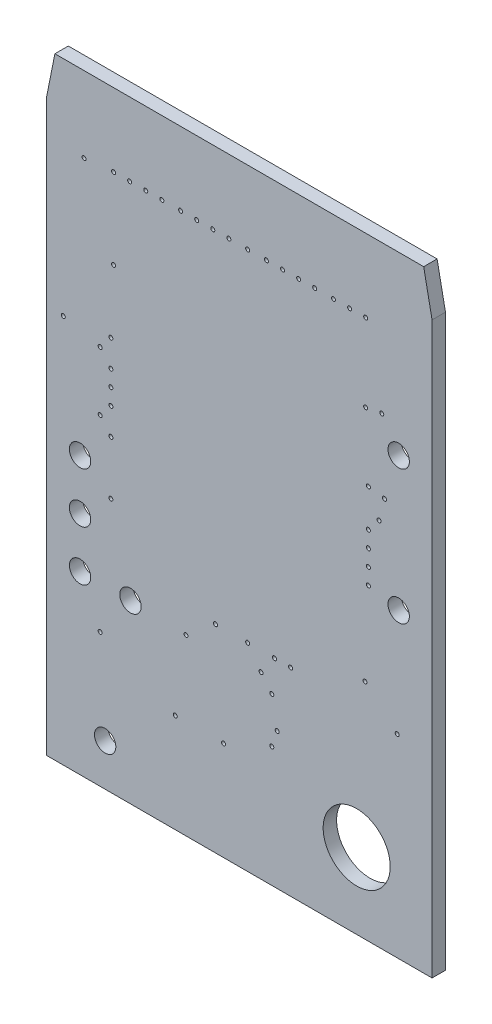
from build123d import *

# Parameters (mm, degrees)
BOARD_OUTLINE_DEPTH = 0.508
SKETCH2_R           = 0.0762
NPTH_DEPTH          = 1.508
SKETCH3_R           = 0.405
SKETCH3_R_2         = 1.27
PTH_DEPTH           = 1.508


with BuildPart() as part:
    # Sketch1 → Board_Outline (new body)
    with BuildSketch(Plane.XY):
        Polygon((0, 0), (0, 21.59), (0.3175, 23.1775), (14.2875, 23.1775), (14.605, 21.59), (14.605, 0), align=None)
    extrude(amount=BOARD_OUTLINE_DEPTH)

    # Sketch2 → NPTH (cut, through all)
    with BuildSketch(Plane.XY):
        with Locations((1.4224, 20.3073)):
            Circle(SKETCH2_R)
        with Locations((8.5344, 4.5593)):
            Circle(SKETCH2_R)
        with Locations((12.7, 17.5641)):
            Circle(SKETCH2_R)
        with Locations((12.065, 8.4582)):
            Circle(SKETCH2_R)
        with Locations((13.2842, 7.3406)):
            Circle(SKETCH2_R)
        with Locations((0.635, 14.732)):
            Circle(SKETCH2_R)
        with Locations((3.1496, 20.4089)):
            Circle(SKETCH2_R)
        with Locations((2.4384, 14.9225)):
            Circle(SKETCH2_R)
        with Locations((2.54, 20.4089)):
            Circle(SKETCH2_R)
        with Locations((2.54, 17.3609)):
            Circle(SKETCH2_R)
        with Locations((3.7592, 20.4089)):
            Circle(SKETCH2_R)
        with Locations((2.032, 14.4145)):
            Circle(SKETCH2_R)
        with Locations((4.3688, 20.4089)):
            Circle(SKETCH2_R)
        with Locations((2.4384, 13.9065)):
            Circle(SKETCH2_R)
        with Locations((5.08, 20.4089)):
            Circle(SKETCH2_R)
        with Locations((2.4384, 13.2969)):
            Circle(SKETCH2_R)
        with Locations((5.6896, 20.4089)):
            Circle(SKETCH2_R)
        with Locations((2.4384, 12.6873)):
            Circle(SKETCH2_R)
        with Locations((6.2992, 20.4089)):
            Circle(SKETCH2_R)
        with Locations((2.032, 12.1793)):
            Circle(SKETCH2_R)
        with Locations((6.9088, 20.4089)):
            Circle(SKETCH2_R)
        with Locations((2.4384, 11.6713)):
            Circle(SKETCH2_R)
        with Locations((7.62, 20.4089)):
            Circle(SKETCH2_R)
        with Locations((12.192, 11.6713)):
            Circle(SKETCH2_R)
        with Locations((12.0904, 20.4089)):
            Circle(SKETCH2_R)
        with Locations((12.0904, 17.4625)):
            Circle(SKETCH2_R)
        with Locations((11.4808, 20.4089)):
            Circle(SKETCH2_R)
        with Locations((12.192, 14.9225)):
            Circle(SKETCH2_R)
        with Locations((10.8712, 20.4089)):
            Circle(SKETCH2_R)
        with Locations((12.8016, 14.8209)):
            Circle(SKETCH2_R)
        with Locations((10.16, 20.4089)):
            Circle(SKETCH2_R)
        with Locations((12.5984, 14.0081)):
            Circle(SKETCH2_R)
        with Locations((9.5504, 20.4089)):
            Circle(SKETCH2_R)
        with Locations((12.192, 13.5001)):
            Circle(SKETCH2_R)
        with Locations((8.9408, 20.4089)):
            Circle(SKETCH2_R)
        with Locations((12.192, 12.8905)):
            Circle(SKETCH2_R)
        with Locations((8.3312, 20.4089)):
            Circle(SKETCH2_R)
        with Locations((12.192, 12.2809)):
            Circle(SKETCH2_R)
        with Locations((6.4008, 7.5057)):
            Circle(SKETCH2_R)
        with Locations((4.8768, 3.7465)):
            Circle(SKETCH2_R)
        with Locations((2.032, 5.0673)):
            Circle(SKETCH2_R)
        with Locations((5.2832, 6.5913)):
            Circle(SKETCH2_R)
        with Locations((7.62, 7.5057)):
            Circle(SKETCH2_R)
        with Locations((8.5344, 6.2865)):
            Circle(SKETCH2_R)
        with Locations((6.7056, 3.7465)):
            Circle(SKETCH2_R)
        with Locations((8.636, 7.5057)):
            Circle(SKETCH2_R)
        with Locations((9.2456, 7.5057)):
            Circle(SKETCH2_R)
        with Locations((8.128, 6.7945)):
            Circle(SKETCH2_R)
        with Locations((2.4384, 9.6393)):
            Circle(SKETCH2_R)
        with Locations((8.7376, 5.1689)):
            Circle(SKETCH2_R)
    extrude(amount=NPTH_DEPTH, mode=Mode.SUBTRACT)

    # Sketch3 → PTH (cut, through all)
    with BuildSketch(Plane.XY):
        with Locations((1.27, 8.57)):
            Circle(SKETCH3_R)
        with Locations((2.22, 1.59)):
            Circle(SKETCH3_R)
        with Locations((1.27, 10.48)):
            Circle(SKETCH3_R)
        with Locations((11.75, 2.86)):
            Circle(SKETCH3_R_2)
        with Locations((1.27, 6.67)):
            Circle(SKETCH3_R)
        with Locations((3.18, 6.67)):
            Circle(SKETCH3_R)
        with Locations((13.34, 16.51)):
            Circle(SKETCH3_R)
        with Locations((13.34, 11.43)):
            Circle(SKETCH3_R)
    extrude(amount=PTH_DEPTH, mode=Mode.SUBTRACT)


solid = part.part
